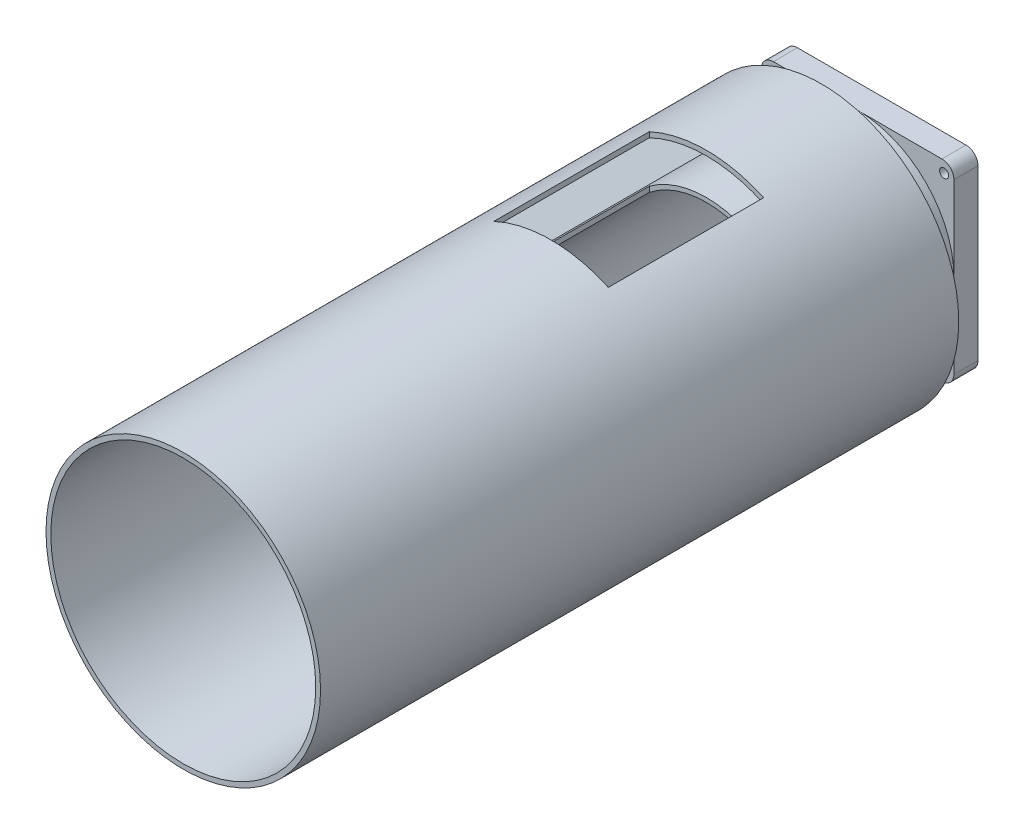
from build123d import *

# Parameters (mm, degrees)
SKETCH1_R           = 1.875000007
SKETCH1_R_2         = 1.875000005
SKETCH1_R_3         = 1.874999993
SKETCH1_R_4         = 1.874999991
SKETCH1_R_5         = 38.25
BOSS_EXTRUDE1_DEPTH = 5
SKETCH2_R           = 40
SKETCH2_R_2         = 38.25
BOSS_EXTRUDE2_DEPTH = 200
SKETCH3_R           = 57
SKETCH3_R_2         = 55
BOSS_EXTRUDE3_DEPTH = 185
SKETCH4_W           = 47.5
SKETCH4_H           = 64.5
CUT_EXTRUDE1_DEPTH  = 221.279368076
BOSS_EXTRUDE4_DEPTH = 2
SKETCH6_R           = 57
SKETCH6_R_2         = 55
BOSS_EXTRUDE5_DEPTH = 80


with BuildPart() as part:
    # Sketch1 → Boss-Extrude1 (new, symmetric)
    with BuildSketch(Plane.XY):
        with BuildLine():
            Line((35, 40), (-35, 40))
            ThreePointArc((-35, 40), (-38.535031951, 38.536035991), (-40, 35.001420011))
            Line((-40, 35.001420011), (-40, -34.998579989))
            ThreePointArc((-40, -34.998579989), (-38.53603605, -38.535031892), (-35, -40))
            Line((-35, -40), (35, -40))
            ThreePointArc((35, -40), (38.53603605, -38.535031892), (40, -34.998579989))
            Line((40, -34.998579989), (40, 35.001420011))
            ThreePointArc((40, 35.001420011), (38.535031951, 38.536035991), (35, 40))
        make_face()
        with Locations((-35.920000129, 35.335989014)):
            Circle(SKETCH1_R, mode=Mode.SUBTRACT)
        with Locations((-35.920000129, -35.919999922)):
            Circle(SKETCH1_R_2, mode=Mode.SUBTRACT)
        with Locations((35.920000129, 35.335989014)):
            Circle(SKETCH1_R_3, mode=Mode.SUBTRACT)
        with Locations((35.920000129, -35.919999922)):
            Circle(SKETCH1_R_4, mode=Mode.SUBTRACT)
        Circle(SKETCH1_R_5, mode=Mode.SUBTRACT)
    extrude(amount=BOSS_EXTRUDE1_DEPTH, both=True)


with BuildPart() as body_2:
    # Sketch2 → Boss-Extrude2 (new body)
    with BuildSketch(Plane.XY.offset(5)):
        Circle(SKETCH2_R)
        Circle(SKETCH2_R_2, mode=Mode.SUBTRACT)
    extrude(amount=BOSS_EXTRUDE2_DEPTH)


with BuildPart() as body_3:
    # Sketch3 → Boss-Extrude3 (new, through all)
    # profile 1 of 4: a face of its own
    with BuildSketch(Plane.XY.offset(20)):
        Circle(SKETCH3_R)
        Circle(SKETCH3_R_2, mode=Mode.SUBTRACT)
    # profile 2 of 4: a face of its own
    with BuildSketch(Plane.XY.offset(20)):
        with BuildLine():
            ThreePointArc((1.75, -38.209946349), (0, -38.25), (-1.75, -38.209946349))
            Line((-1.75, -38.209946349), (-1.75, -54.972152041))
            ThreePointArc((-1.75, -54.972152041), (0, -55), (1.75, -54.972152041))
            Line((1.75, -54.972152041), (1.75, -38.209946349))
        make_face()
    # profile 3 of 4: a face of its own
    with BuildSketch(Plane.XY.offset(20)):
        with BuildLine():
            Line((-48.482280168, 25.970531564), (-33.965784216, 17.589428718))
            ThreePointArc((-33.965784216, 17.589428718), (-33.125471695, 19.125), (-32.215784216, 20.620517631))
            Line((-32.215784216, 20.620517631), (-46.732280168, 29.001620477))
            ThreePointArc((-46.732280168, 29.001620477), (-47.631397208, 27.5), (-48.482280168, 25.970531564))
        make_face()
    # profile 4 of 4: a face of its own
    with BuildSketch(Plane.XY.offset(20)):
        with BuildLine():
            Line((46.732280168, 29.001620477), (32.215784216, 20.620517631))
            ThreePointArc((32.215784216, 20.620517631), (33.125471695, 19.125), (33.965784216, 17.589428718))
            Line((33.965784216, 17.589428718), (48.482280168, 25.970531564))
            ThreePointArc((48.482280168, 25.970531564), (47.631397208, 27.5), (46.732280168, 29.001620477))
        make_face()
    extrude(amount=BOSS_EXTRUDE3_DEPTH)


with BuildPart() as cut_extrude1_tool:
    # Sketch4 → Cut-Extrude1 (new, through all)
    with BuildSketch(Plane(origin=(0, 0, 0), x_dir=(1, 0, 0), z_dir=(0, 1, 0))):
        with Locations((0, -100)):
            Rectangle(SKETCH4_W, SKETCH4_H)
    extrude(amount=CUT_EXTRUDE1_DEPTH)


with BuildPart() as body_2_1:
    add(body_2.part)

    # Cut-Extrude1: cut by cut_extrude1_tool
    add(cut_extrude1_tool.part, mode=Mode.SUBTRACT)



with BuildPart() as body_3_1:
    add(body_3.part)

    # Cut-Extrude1: cut by cut_extrude1_tool
    add(cut_extrude1_tool.part, mode=Mode.SUBTRACT)


with BuildPart() as body_2_2:
    add(body_2_1.part)

    add(body_3_1.part)  # Boss-Extrude4 merges body 3
    # Sketch5 → Boss-Extrude4 (add)
    with BuildSketch(Plane(origin=(0, 0, 132.25), x_dir=(-1, 0, 0), z_dir=(0, 0, -1))):
        with BuildLine():
            Line((23.75, 49.607837082), (23.75, 32.185982974))
            ThreePointArc((23.75, 32.185982974), (0, 40), (-23.75, 32.185982974))
            Line((-23.75, 32.185982974), (-23.75, 49.607837082))
            ThreePointArc((-23.75, 49.607837082), (0, 55), (23.75, 49.607837082))
        make_face()
    extrude(amount=-BOSS_EXTRUDE4_DEPTH)

    # Sketch6 → Boss-Extrude5 (add)
    with BuildSketch(Plane.XY.offset(205)):
        Circle(SKETCH6_R)
        with Locations(Location((0, 0, 0), (0, 0, 151.823355278))):
            Circle(SKETCH6_R_2, mode=Mode.SUBTRACT)
    extrude(amount=BOSS_EXTRUDE5_DEPTH)


solid = Compound([part.part, body_2_2.part])
